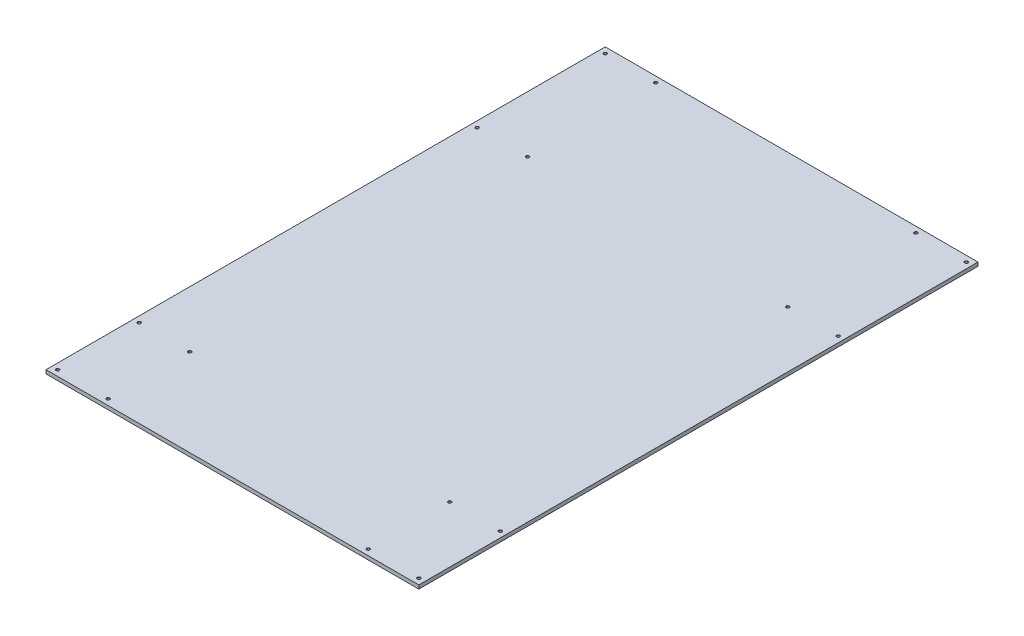
from build123d import *

# Parameters (mm, degrees)
SKETCH1_W                                 = 1219.2
SKETCH1_H                                 = 1828.8
BOSS_EXTRUDE1_DEPTH                       = 12
F_23_64_0_35938_DIAMETER_HOLE2_AT_2_COUNT = 2
F_23_64_0_35938_DIAMETER_HOLE2_AT_2_PITCH = 165.1
F_23_64_0_35938_DIAMETER_HOLE2_AT_3_COUNT = 2
F_23_64_0_35938_DIAMETER_HOLE2_AT_3_PITCH = 450.447355415
F_23_64_0_35938_DIAMETER_HOLE2_AT_4_COUNT = 2
F_23_64_0_35938_DIAMETER_HOLE2_AT_4_PITCH = 419.1
F_23_64_0_35938_DIAMETER_HOLE2_AT_5_COUNT = 2
F_23_64_0_35938_DIAMETER_HOLE2_AT_5_PITCH = 1524
F_23_64_0_35938_DIAMETER_HOLE2_AT_6_COUNT = 2
F_23_64_0_35938_DIAMETER_HOLE2_AT_6_PITCH = 1532.916830751
F_23_64_0_35938_DIAMETER_HOLE2_AT_7_COUNT = 2
F_23_64_0_35938_DIAMETER_HOLE2_AT_7_PITCH = 1798.29488683
F_23_64_0_35938_DIAMETER_HOLE2_AT_8_COUNT = 2
F_23_64_0_35938_DIAMETER_HOLE2_AT_8_PITCH = 1790.7


with BuildPart() as part:
    # Sketch1 → Boss-Extrude1 (new body)
    with BuildSketch(Plane(origin=(0, 0, 0), x_dir=(1, 0, 0), z_dir=(0, 1, 0))):
        Rectangle(SKETCH1_W, SKETCH1_H)
    extrude(amount=-BOSS_EXTRUDE1_DEPTH)

    # Sketch6 → 23_64 _0.35938_ Diameter Hole2 (revolve, cut)
    with BuildSketch(Plane(origin=(-590.55, 0, -895.35), x_dir=(0, 0, 1), z_dir=(1, 0, 0))):
        Polygon((0, 0), (0, 9.921875), (4.564126, 7.179471426), (4.564126, 0.635), (5.199126, 0), align=None)
    f_23_64_0_35938_diameter_hole2 = revolve(axis=Axis((-590.55, 6.35, -895.35), (0, -1, 0)), mode=Mode.SUBTRACT)

    # 23_64 _0.35938_ Diameter Hole2 at 2: 23_64 _0.35938_ Diameter Hole2 ×2
    with Locations(*[(i * F_23_64_0_35938_DIAMETER_HOLE2_AT_2_PITCH, 0, 0) for i in range(1, F_23_64_0_35938_DIAMETER_HOLE2_AT_2_COUNT)]):
        add(f_23_64_0_35938_diameter_hole2, mode=Mode.SUBTRACT)

    # 23_64 _0.35938_ Diameter Hole2 at 3: 23_64 _0.35938_ Diameter Hole2 ×2
    with Locations(*[Vector(0.3665245183824908, 0, 0.9304083928170915) * (i * F_23_64_0_35938_DIAMETER_HOLE2_AT_3_PITCH) for i in range(1, F_23_64_0_35938_DIAMETER_HOLE2_AT_3_COUNT)]):
        add(f_23_64_0_35938_diameter_hole2, mode=Mode.SUBTRACT)

    # 23_64 _0.35938_ Diameter Hole2 at 4: 23_64 _0.35938_ Diameter Hole2 ×2
    with Locations(*[(0, 0, i * F_23_64_0_35938_DIAMETER_HOLE2_AT_4_PITCH) for i in range(1, F_23_64_0_35938_DIAMETER_HOLE2_AT_4_COUNT)]):
        add(f_23_64_0_35938_diameter_hole2, mode=Mode.SUBTRACT)

    # 23_64 _0.35938_ Diameter Hole2 at 5: 23_64 _0.35938_ Diameter Hole2 ×2
    with Locations(*[(0, 0, i * F_23_64_0_35938_DIAMETER_HOLE2_AT_5_PITCH) for i in range(1, F_23_64_0_35938_DIAMETER_HOLE2_AT_5_COUNT)]):
        add(f_23_64_0_35938_diameter_hole2, mode=Mode.SUBTRACT)

    # 23_64 _0.35938_ Diameter Hole2 at 6: 23_64 _0.35938_ Diameter Hole2 ×2
    with Locations(*[Vector(0.1077031686833943, 0, 0.9941830955390242) * (i * F_23_64_0_35938_DIAMETER_HOLE2_AT_6_PITCH) for i in range(1, F_23_64_0_35938_DIAMETER_HOLE2_AT_6_COUNT)]):
        add(f_23_64_0_35938_diameter_hole2, mode=Mode.SUBTRACT)

    # 23_64 _0.35938_ Diameter Hole2 at 7: 23_64 _0.35938_ Diameter Hole2 ×2
    with Locations(*[Vector(0.09180919170103835, 0, 0.9957766176804926) * (i * F_23_64_0_35938_DIAMETER_HOLE2_AT_7_PITCH) for i in range(1, F_23_64_0_35938_DIAMETER_HOLE2_AT_7_COUNT)]):
        add(f_23_64_0_35938_diameter_hole2, mode=Mode.SUBTRACT)

    # 23_64 _0.35938_ Diameter Hole2 at 8: 23_64 _0.35938_ Diameter Hole2 ×2
    with Locations(*[(0, 0, i * F_23_64_0_35938_DIAMETER_HOLE2_AT_8_PITCH) for i in range(1, F_23_64_0_35938_DIAMETER_HOLE2_AT_8_COUNT)]):
        add(f_23_64_0_35938_diameter_hole2, mode=Mode.SUBTRACT)

    # Mirror1: 23_64 _0.35938_ Diameter Hole2 across plane
    add(f_23_64_0_35938_diameter_hole2.mirror(Plane(origin=(0, 0, 0), x_dir=(0, 0, 1), z_dir=(1, 0, 0))), mode=Mode.SUBTRACT)

    # Mirror1 copy 1 sketch → Mirror1 copy 1 (revolve, cut)
    with BuildSketch(Plane(origin=(425.45, 0, -895.35), x_dir=(0, 0, 1), z_dir=(-1, 0, 0))):
        Polygon((0, 0), (0, -9.921875), (4.564126, -7.179471426), (4.564126, -0.635), (5.199126, 0), align=None)
    revolve(axis=Axis((425.45, 6.35, -895.35), (0, 1, 0)), mode=Mode.SUBTRACT)

    # Mirror1 copy 2 sketch → Mirror1 copy 2 (revolve, cut)
    with BuildSketch(Plane(origin=(425.45, 0, -476.25), x_dir=(0, 0, 1), z_dir=(-1, 0, 0))):
        Polygon((0, 0), (0, -9.921875), (4.564126, -7.179471426), (4.564126, -0.635), (5.199126, 0), align=None)
    revolve(axis=Axis((425.45, 6.35, -476.25), (0, 1, 0)), mode=Mode.SUBTRACT)

    # Mirror1 copy 3 sketch → Mirror1 copy 3 (revolve, cut)
    with BuildSketch(Plane(origin=(590.55, 0, -476.25), x_dir=(0, 0, 1), z_dir=(-1, 0, 0))):
        Polygon((0, 0), (0, -9.921875), (4.564126, -7.179471426), (4.564126, -0.635), (5.199126, 0), align=None)
    revolve(axis=Axis((590.55, 6.35, -476.25), (0, 1, 0)), mode=Mode.SUBTRACT)

    # Mirror1 copy 4 sketch → Mirror1 copy 4 (revolve, cut)
    with BuildSketch(Plane(origin=(590.55, 0, 628.65), x_dir=(0, 0, 1), z_dir=(-1, 0, 0))):
        Polygon((0, 0), (0, -9.921875), (4.564126, -7.179471426), (4.564126, -0.635), (5.199126, 0), align=None)
    revolve(axis=Axis((590.55, 6.35, 628.65), (0, 1, 0)), mode=Mode.SUBTRACT)

    # Mirror1 copy 5 sketch → Mirror1 copy 5 (revolve, cut)
    with BuildSketch(Plane(origin=(425.45, 0, 628.65), x_dir=(0, 0, 1), z_dir=(-1, 0, 0))):
        Polygon((0, 0), (0, -9.921875), (4.564126, -7.179471426), (4.564126, -0.635), (5.199126, 0), align=None)
    revolve(axis=Axis((425.45, 6.35, 628.65), (0, 1, 0)), mode=Mode.SUBTRACT)

    # Mirror1 copy 6 sketch → Mirror1 copy 6 (revolve, cut)
    with BuildSketch(Plane(origin=(425.45, 0, 895.35), x_dir=(0, 0, 1), z_dir=(-1, 0, 0))):
        Polygon((0, 0), (0, -9.921875), (4.564126, -7.179471426), (4.564126, -0.635), (5.199126, 0), align=None)
    revolve(axis=Axis((425.45, 6.35, 895.35), (0, 1, 0)), mode=Mode.SUBTRACT)

    # Mirror1 copy 7 sketch → Mirror1 copy 7 (revolve, cut)
    with BuildSketch(Plane(origin=(590.55, 0, 895.35), x_dir=(0, 0, 1), z_dir=(-1, 0, 0))):
        Polygon((0, 0), (0, -9.921875), (4.564126, -7.179471426), (4.564126, -0.635), (5.199126, 0), align=None)
    revolve(axis=Axis((590.55, 6.35, 895.35), (0, 1, 0)), mode=Mode.SUBTRACT)


solid = part.part
